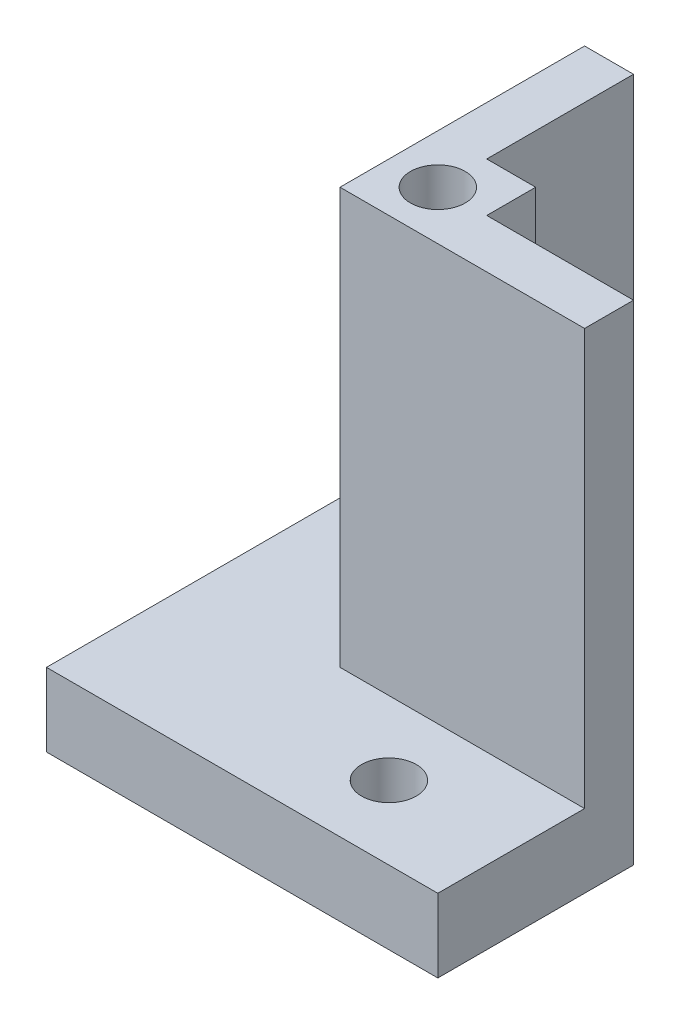
from build123d import *

# Parameters (mm, degrees)
BOSS_EXTRUDE4_DEPTH                      = 25.4
SKETCH5_R                                = 1.4224
CAGE_MOUNTING_HOLE_4_40_TAPPED_DEPTH     = 3.81
BOSS_EXTRUDE5_DEPTH                      = 3.81
SKETCH7_R                                = 1.4224
BASE_MOUNTING_HOLES_4_40_CLEARANCE_DEPTH = 3.81


with BuildPart() as part:
    # Sketch4 → Boss-Extrude4 (new body)
    with BuildSketch(Plane(origin=(0, 0, 0), x_dir=(1, 0, 0), z_dir=(0, 1, 0))):
        Polygon((-2.732505263, 2.4892), (-2.732505263, 10.1092), (-0.192505263, 10.1092), (-0.192505263, 2.4892), (2.347494737, 2.4892), (2.347494737, -0.0508), (9.967494737, -0.0508), (9.967494737, -2.5908), (2.347494737, -2.5908), (-2.732505263, -2.5908), align=None)
    extrude(amount=BOSS_EXTRUDE4_DEPTH)

    # Sketch5 → Cage Mounting Hole (4-40 Tapped) (cut)
    with BuildSketch(Plane(origin=(0, 25.4, 0), x_dir=(1, 0, 0), z_dir=(0, 1, 0))):
        with Locations((-0.192505263, -0.0508)):
            Circle(SKETCH5_R)
    extrude(amount=-CAGE_MOUNTING_HOLE_4_40_TAPPED_DEPTH, mode=Mode.SUBTRACT)

    # Sketch6 → Boss-Extrude5 (add)
    with BuildSketch(Plane.XZ):
        Polygon((9.967494737, 2.5908), (9.967494737, 10.2108), (-10.352505263, 10.2108), (-10.352505263, -10.1092), (-2.732505263, -10.1092), (-2.732505263, 2.5908), align=None)
    extrude(amount=-BOSS_EXTRUDE5_DEPTH)

    # Sketch7 → Base Mounting Holes (4-40 Clearance) (cut)
    with BuildSketch(Plane(origin=(0, 3.81, 0), x_dir=(1, 0, 0), z_dir=(0, 1, 0))):
        with Locations((-6.542505263, 3.7592)):
            Circle(SKETCH7_R)
        with Locations((3.617494737, -6.4008)):
            Circle(SKETCH7_R)
    extrude(amount=-BASE_MOUNTING_HOLES_4_40_CLEARANCE_DEPTH, mode=Mode.SUBTRACT)


solid = part.part
